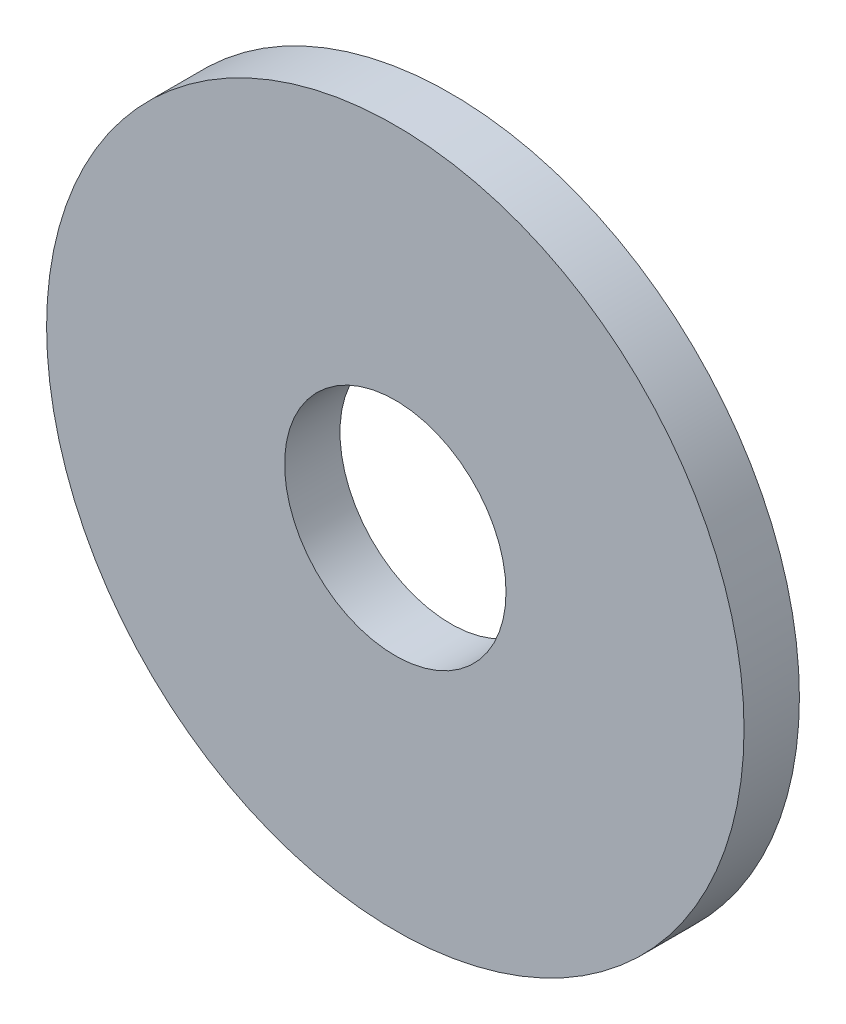
from build123d import *

# Parameters (mm, degrees)
SKETCH1_R      = 8.001
SKETCH1_R_2    = 2.54
EXTRUDE1_DEPTH = 1.27


with BuildPart() as part:
    # Sketch1 → Extrude1 (new body)
    with BuildSketch(Plane.XY):
        Circle(SKETCH1_R)
        Circle(SKETCH1_R_2, mode=Mode.SUBTRACT)
    extrude(amount=-EXTRUDE1_DEPTH)


solid = part.part
